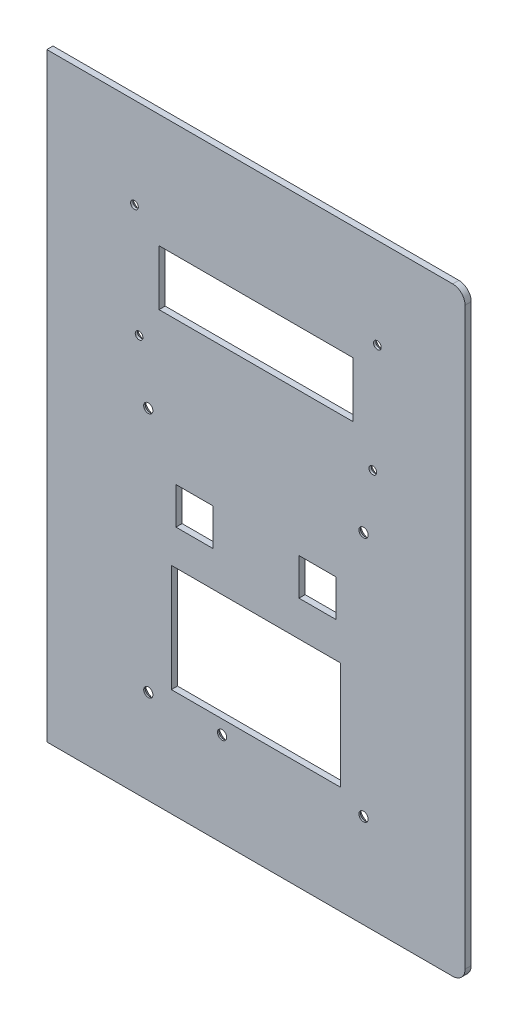
from build123d import *

# Parameters (mm, degrees)
ESQUISSE1_W      = 136
ESQUISSE1_H      = 195
ESQUISSE1_R      = 1.25
ESQUISSE1_R_2    = 1.5
ESQUISSE1_W_2    = 63
ESQUISSE1_H_2    = 18
ESQUISSE1_W_3    = 12
ESQUISSE1_H_3    = 12
ESQUISSE1_W_4    = 55
ESQUISSE1_H_4    = 35
EXTRUSION1_DEPTH = 1
CHANFREIN1_SIZE  = 1.5
CONG_1_R         = 4
CHANFREIN2_SIZE  = 1.25


with BuildPart() as part:
    # Esquisse1 → Extrusion1 (new body, symmetric)
    with BuildSketch(Plane.XY):
        with Locations((-68, 97.5)):
            Rectangle(ESQUISSE1_W, ESQUISSE1_H)
        with Locations((-107.5, 165.5)):
            Circle(ESQUISSE1_R, mode=Mode.SUBTRACT)
        with Locations((-28.5, 165.5)):
            Circle(ESQUISSE1_R, mode=Mode.SUBTRACT)
        with Locations((-30, 129.5)):
            Circle(ESQUISSE1_R, mode=Mode.SUBTRACT)
        with Locations((-106, 129.5)):
            Circle(ESQUISSE1_R, mode=Mode.SUBTRACT)
        with Locations((-103, 110.5)):
            Circle(ESQUISSE1_R_2, mode=Mode.SUBTRACT)
        with Locations((-33, 110.5)):
            Circle(ESQUISSE1_R_2, mode=Mode.SUBTRACT)
        with Locations((-33, 30.5)):
            Circle(ESQUISSE1_R_2, mode=Mode.SUBTRACT)
        with Locations((-103, 30.5)):
            Circle(ESQUISSE1_R_2, mode=Mode.SUBTRACT)
        with Locations((-79, 30.5)):
            Circle(ESQUISSE1_R_2, mode=Mode.SUBTRACT)
        with Locations((-68, 149)):
            Rectangle(ESQUISSE1_W_2, ESQUISSE1_H_2, mode=Mode.SUBTRACT)
        with Locations((-88, 87.5)):
            Rectangle(ESQUISSE1_W_3, ESQUISSE1_H_3, mode=Mode.SUBTRACT)
        with Locations((-48, 87.5)):
            Rectangle(ESQUISSE1_W_3, ESQUISSE1_H_3, mode=Mode.SUBTRACT)
        with Locations((-68, 52.5)):
            Rectangle(ESQUISSE1_W_4, ESQUISSE1_H_4, mode=Mode.SUBTRACT)
    extrude(amount=EXTRUSION1_DEPTH, both=True)

    # Chanfrein1
    chanfrein1_edges = [part.edges().sort_by_distance(p)[0] for p in [
        (-104.5, 110.5, -1),
        (-34.5, 110.5, -1),
        (-34.5, 30.5, -1),
        (-104.5, 30.5, -1),
        (-80.5, 30.5, -1),
    ]]
    chamfer(chanfrein1_edges, length=CHANFREIN1_SIZE)

    # Congé1
    cong_1_edges = [part.edges().sort_by_distance(p)[0] for p in [
        (0, 0, 0),
        (0, 195, 0),
    ]]
    fillet(cong_1_edges, radius=CONG_1_R)

    # Chanfrein2
    chanfrein2_edges = [part.edges().sort_by_distance(p)[0] for p in [
        (-108.75, 165.5, -1),
        (-29.75, 165.5, -1),
        (-31.25, 129.5, -1),
        (-107.25, 129.5, -1),
    ]]
    chamfer(chanfrein2_edges, length=CHANFREIN2_SIZE)


solid = part.part
